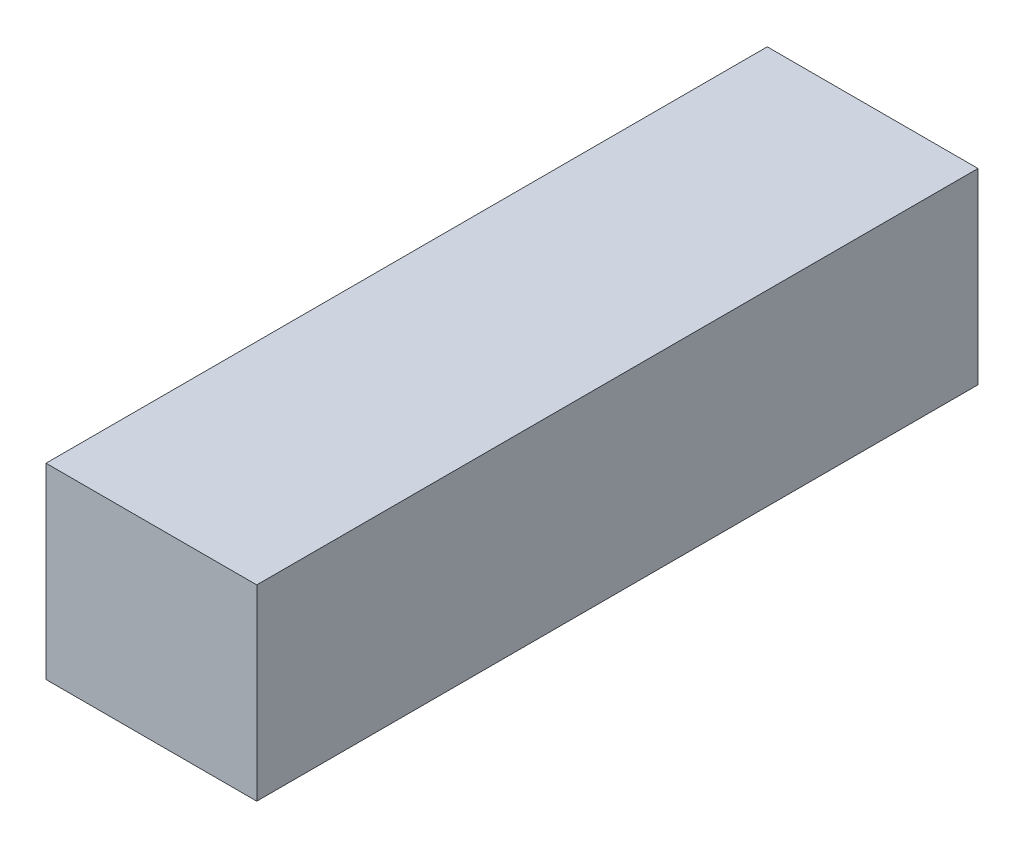
from build123d import *

# Parameters (mm, degrees)
SKETCH1_W           = 45
SKETCH1_H           = 40
BOSS_EXTRUDE1_DEPTH = 154


with BuildPart() as part:
    # Sketch1 → Boss-Extrude1 (new body)
    with BuildSketch(Plane.XY):
        Rectangle(SKETCH1_W, SKETCH1_H)
    extrude(amount=BOSS_EXTRUDE1_DEPTH)


solid = part.part
